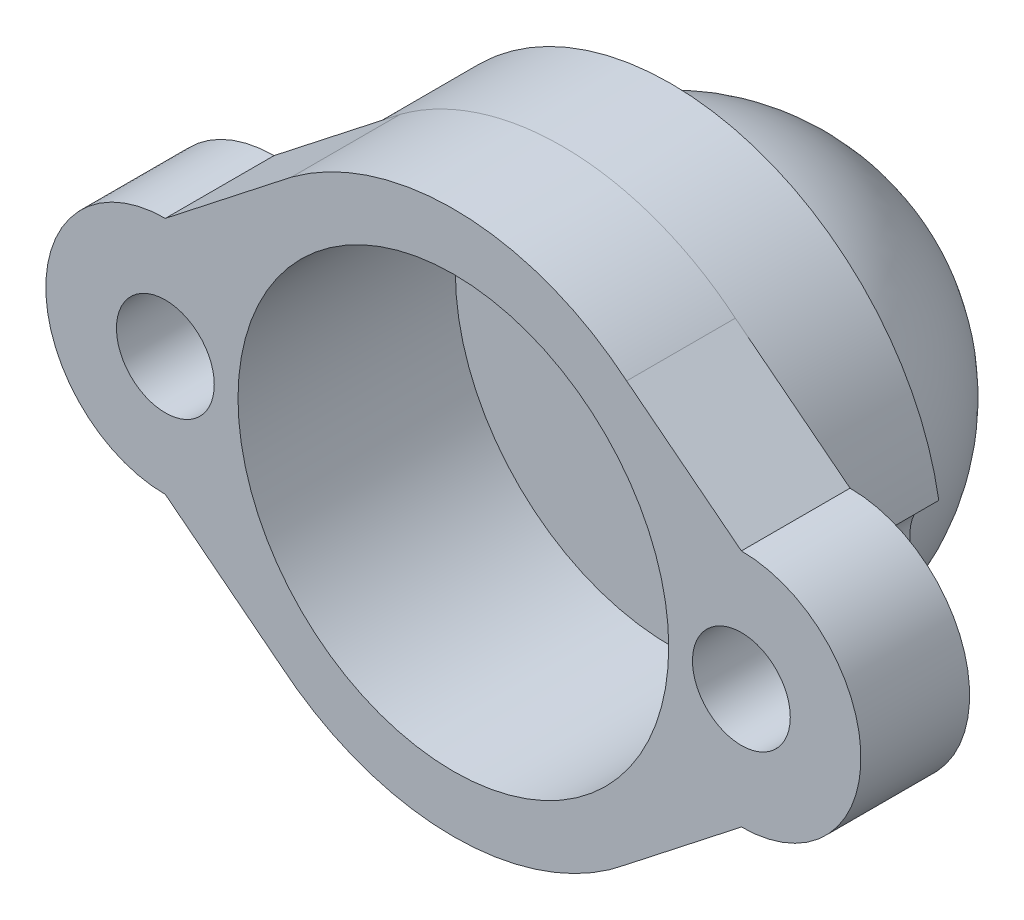
from build123d import *
from build123d.topology import SkipClean

# Parameters (mm, degrees)
SKETCH1_R           = 1.143
SKETCH1_R_2         = 5.0330227
BOSS_EXTRUDE1_DEPTH = 2.54
BOSS_EXTRUDE2_START = 2.54
SKETCH2_R           = 5.0330227
BOSS_EXTRUDE2_DEPTH = 2.54


with BuildPart() as part:
    # Sketch1 → Boss-Extrude1 (new body)
    with BuildSketch(Plane.XY):
        with BuildLine():
            ThreePointArc((-5.574053245, -0.790421797), (-8.368053245, -3.584421797), (-5.574053245, -6.378421797))
            Line((-5.574053245, -6.378421797), (-2.89267695, -8.478510283))
            ThreePointArc((-2.89267695, -8.478510283), (1.156946755, -9.936709122), (5.206570461, -8.478510283))
            Line((5.206570461, -8.478510283), (7.887946755, -6.378421797))
            ThreePointArc((7.887946755, -6.378421797), (10.681946755, -3.584421797), (7.887946755, -0.790421797))
            Line((7.887946755, -0.790421797), (5.206570461, 1.309666689))
            ThreePointArc((5.206570461, 1.309666689), (1.327399862, 2.765578203), (-2.624290324, 1.519870555))
            Line((-2.624290324, 1.519870555), (-2.758483637, 1.414768622))
            Line((-2.758483637, 1.414768622), (-5.574053245, -0.790421797))
        make_face()
        with Locations((-5.574053245, -3.584421797)):
            Circle(SKETCH1_R, mode=Mode.SUBTRACT)
        with Locations((7.887946755, -3.584421797)):
            Circle(SKETCH1_R, mode=Mode.SUBTRACT)
        with Locations((1.156946755, -3.584421797)):
            Circle(SKETCH1_R_2, mode=Mode.SUBTRACT)
    extrude(amount=BOSS_EXTRUDE1_DEPTH)

    # Sketch2 → Boss-Extrude2 (add)
    with SkipClean():  # the faces are left unmerged after this step: merging them gives an invalid solid
        with BuildSketch(Plane(origin=(0, 0, 0), x_dir=(-1, 0, 0), z_dir=(0, 0, -1)).offset(BOSS_EXTRUDE2_START)):
            with BuildLine():
                ThreePointArc((5.106789094, -2.541295144), (-1.156946755, 2.765578203), (-7.420682604, -2.541295144))
                ThreePointArc((-7.420682604, -2.541295144), (-6.744946755, -3.584421797), (-7.420682604, -4.62754845))
                ThreePointArc((-7.420682604, -4.62754845), (-1.156946755, -9.934421797), (5.106789094, -4.62754845))
                ThreePointArc((5.106789094, -4.62754845), (4.431053245, -3.584421797), (5.106789094, -2.541295144))
            make_face()
            with Locations((-1.156946755, -3.584421797)):
                Circle(SKETCH2_R, mode=Mode.SUBTRACT)
        extrude(amount=-BOSS_EXTRUDE2_DEPTH)

    # Sketch5 → Revolve1 (revolve)
    with SkipClean():  # the faces are left unmerged after this step: merging them gives an invalid solid
        with BuildSketch(Plane(origin=(1.156946755, 0, 0), x_dir=(0, 0, -1), z_dir=(1, 0, 0))):
            with BuildLine():
                Line((2.54, -3.584421797), (7.62, -3.584421797))
                ThreePointArc((7.62, -3.584421797), (6.132102448, 0.007680651), (2.54, 1.495578203))
                Line((2.54, 1.495578203), (2.54, -3.584421797))
            make_face()
        revolve(axis=Axis((1.156946755, -3.584421797, -2.54), (0, 0, -1)))


solid = part.part
